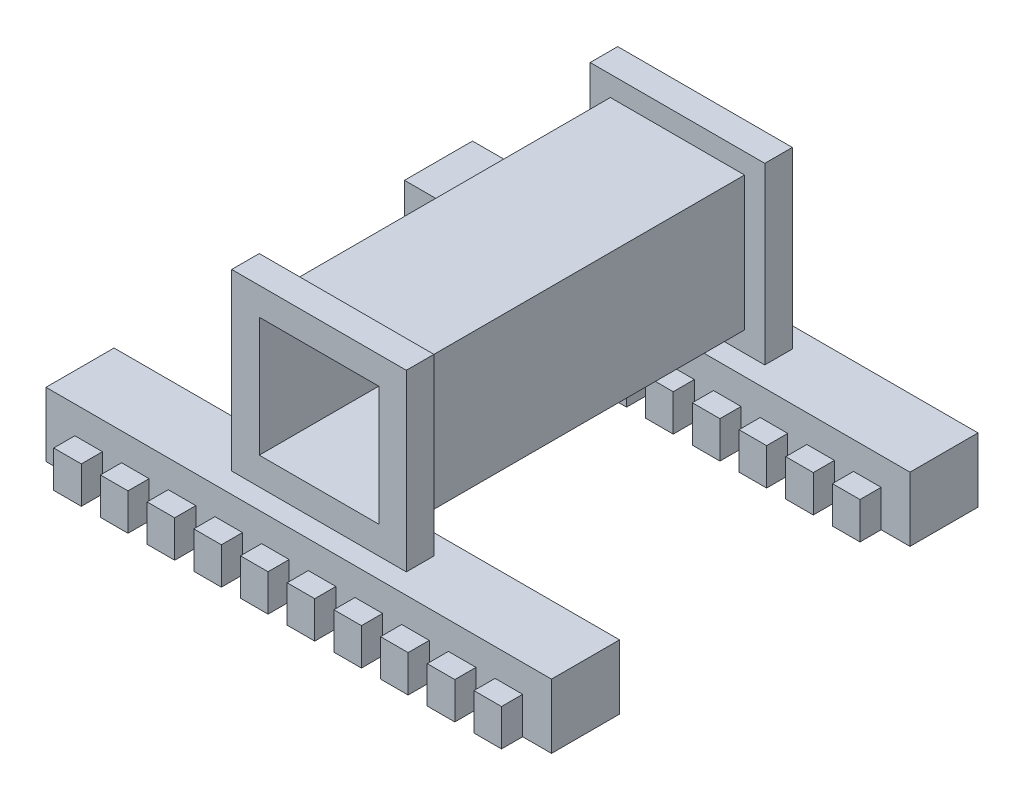
from build123d import *

# Parameters (mm, degrees)
EXTRUDE_1_DEPTH      = 21
SKETCH_1_3_W         = 13
SKETCH_1_3_H         = 13
CUT_EXTRUDE_1_DEPTH  = 21
SKETCH_1_12_W        = 19
SKETCH_1_12_H        = 19
SKETCH_1_12_W_2      = 14.6
SKETCH_1_12_H_2      = 14.6
SKETCH_1_12_W_3      = 13
SKETCH_1_12_H_3      = 13
CUT_EXTRUDE_6_DEPTH  = 18
CUT_EXTRUDE_7_DEPTH  = 14.5
SKETCH_4_W           = 3.504900739
SKETCH_4_H           = 7
SKETCH_4_W_2         = 3.5
EXTRUDE_2_DEPTH      = 27.5
SKETCH_10_W          = 1
SKETCH_10_H          = 7
EXTRUDE_4_DEPTH      = 55
SKETCH_14_W          = 1
SKETCH_14_H          = 7
EXTRUDE_6_DEPTH      = 55
CUT_EXTRUDE_17_DEPTH = 2.3
CUT_EXTRUDE_18_DEPTH = 2.3
CUT_EXTRUDE_19_DEPTH = 2.3
CUT_EXTRUDE_20_DEPTH = 2.3


with BuildPart() as part:
    # 草图1 → 凸台-拉伸1 (new, symmetric)
    with BuildSketch(Plane.XY):
        Polygon((9.5, 9.5), (-9.5, 9.5), (-9.5, -9.5), (-27.5, -9.5), (-27.5, -16.5), (27.5, -16.5), (27.5, -9.5), (9.5, -9.5), align=None)
    extrude(amount=EXTRUDE_1_DEPTH, both=True)

    # 草图1<3> → 切除-拉伸1 (cut, symmetric)
    with BuildSketch(Plane.XY):
        Rectangle(SKETCH_1_3_W, SKETCH_1_3_H)
    extrude(amount=CUT_EXTRUDE_1_DEPTH, both=True, mode=Mode.SUBTRACT)

    # 草图1<12> → 切除-拉伸6 (cut, symmetric)
    # profile 1 of 2: a face of its own
    with BuildSketch(Plane.XY):
        Rectangle(SKETCH_1_12_W, SKETCH_1_12_H)
        Rectangle(SKETCH_1_12_W_2, SKETCH_1_12_H_2, mode=Mode.SUBTRACT)
    # profile 2 of 2: a face of its own
    with BuildSketch(Plane.XY):
        Rectangle(SKETCH_1_12_W_3, SKETCH_1_12_H_3)
    extrude(amount=CUT_EXTRUDE_6_DEPTH, both=True, mode=Mode.SUBTRACT)

    # 草图1<13> → 切除-拉伸7 (cut, symmetric)
    with BuildSketch(Plane.XY):
        Polygon((9.5, -9.5), (-9.5, -9.5), (-27.5, -9.5), (-27.5, -16.5), (27.5, -16.5), (27.5, -9.5), align=None)
    extrude(amount=CUT_EXTRUDE_7_DEPTH, both=True, mode=Mode.SUBTRACT)

    # 草图4 → 凸台-拉伸2 (add, symmetric)
    with BuildSketch(Plane(origin=(0, 0, 0), x_dir=(0, 0, -1), z_dir=(1, 0, 0))):
        with Locations((-22.752450369, -13)):
            Rectangle(SKETCH_4_W, SKETCH_4_H)
        with Locations((22.75, -13)):
            Rectangle(SKETCH_4_W_2, SKETCH_4_H)
    extrude(amount=EXTRUDE_2_DEPTH, both=True)

    # 草图10 → 凸台-拉伸4 (add)
    with BuildSketch(Plane(origin=(27.5, 0, 0), x_dir=(0, 0, -1), z_dir=(1, 0, 0))):
        with Locations((-25.004900739, -13)):
            Rectangle(SKETCH_10_W, SKETCH_10_H)
        with Locations((-14, -13)):
            Rectangle(SKETCH_10_W, SKETCH_10_H)
    extrude(amount=-EXTRUDE_4_DEPTH)

    # 草图14 → 凸台-拉伸6 (add)
    with BuildSketch(Plane(origin=(27.5, 0, 0), x_dir=(0, 0, -1), z_dir=(1, 0, 0))):
        with Locations((14, -13)):
            Rectangle(SKETCH_14_W, SKETCH_14_H)
        with Locations((25, -13)):
            Rectangle(SKETCH_14_W, SKETCH_14_H)
    extrude(amount=-EXTRUDE_6_DEPTH)

    # 草图15 → 切除-拉伸17 (cut)
    with BuildSketch(Plane(origin=(0, 0, -25.5), x_dir=(-1, 0, 0), z_dir=(0, 0, -1))):
        Polygon((-27.5, -9.5), (-27.5, -16.5), (-24.36, -16.5), (-24.36, -12.5), (-22.86, -12.5), (-21.36, -12.5), (-21.36, -16.5), (-19.28, -16.5), (-19.28, -12.5), (-17.78, -12.5), (-16.28, -12.5), (-16.28, -16.5), (-14.2, -16.5), (-14.2, -12.5), (-12.7, -12.5), (-11.2, -12.5), (-11.2, -16.5), (-9.12, -16.5), (-9.12, -12.5), (-7.62, -12.5), (-6.12, -12.5), (-6.12, -16.5), (-4.04, -16.5), (-4.04, -12.5), (-2.54, -12.5), (-1.04, -12.5), (-1.04, -16.5), (1.04, -16.5), (1.04, -12.5), (2.54, -12.5), (4.04, -12.5), (4.04, -16.5), (6.12, -16.5), (6.12, -12.5), (7.62, -12.5), (9.12, -12.5), (9.12, -16.5), (11.2, -16.5), (11.2, -12.5), (12.7, -12.5), (14.2, -12.5), (14.2, -16.5), (16.28, -16.5), (16.28, -12.5), (17.78, -12.5), (19.28, -12.5), (19.28, -16.5), (21.36, -16.5), (21.36, -12.5), (22.86, -12.5), (24.36, -12.5), (24.36, -16.5), (27.5, -16.5), (27.5, -9.5), align=None)
    extrude(amount=-CUT_EXTRUDE_17_DEPTH, mode=Mode.SUBTRACT)

    # 草图16 → 切除-拉伸18 (cut)
    with BuildSketch(Plane(origin=(0, 0, 13.5), x_dir=(-1, 0, 0), z_dir=(0, 0, -1))):
        Polygon((27.5, -9.5), (-27.5, -9.5), (-27.5, -16.5), (-24.36, -16.5), (-24.36, -12.5), (-21.36, -12.5), (-21.36, -16.5), (-19.28, -16.5), (-19.28, -12.5), (-16.28, -12.5), (-16.28, -16.5), (-14.2, -16.5), (-14.2, -12.5), (-11.2, -12.5), (-11.2, -16.5), (-9.12, -16.5), (-9.12, -12.5), (-6.12, -12.5), (-6.12, -16.5), (-4.04, -16.5), (-4.04, -12.5), (-1.04, -12.5), (-1.04, -16.5), (1.04, -16.5), (1.04, -12.5), (4.04, -12.5), (4.04, -16.5), (6.12, -16.5), (6.12, -12.5), (9.12, -12.5), (9.12, -16.5), (11.2, -16.5), (11.2, -12.5), (14.2, -12.5), (14.2, -16.5), (16.28, -16.5), (16.28, -12.5), (19.28, -12.5), (19.28, -16.5), (21.36, -16.5), (21.36, -12.5), (24.36, -12.5), (24.36, -16.5), (27.5, -16.5), align=None)
    extrude(amount=-CUT_EXTRUDE_18_DEPTH, mode=Mode.SUBTRACT)

    # 草图17 → 切除-拉伸19 (cut)
    with BuildSketch(Plane.XY.offset(-13.5)):
        Polygon((24.36, -16.5), (27.5, -16.5), (27.5, -9.5), (-27.5, -9.5), (-27.5, -16.5), (-24.36, -16.5), (-24.36, -12.5), (-21.36, -12.5), (-21.36, -16.5), (-19.28, -16.5), (-19.28, -12.5), (-16.28, -12.5), (-16.28, -16.5), (-14.2, -16.5), (-14.2, -12.5), (-11.2, -12.5), (-11.2, -16.5), (-9.12, -16.5), (-9.12, -12.5), (-6.12, -12.5), (-6.12, -16.5), (-4.04, -16.5), (-4.04, -12.5), (-1.04, -12.5), (-1.04, -16.5), (1.04, -16.5), (1.04, -12.5), (4.04, -12.5), (4.04, -16.5), (6.12, -16.5), (6.12, -12.5), (9.12, -12.5), (9.12, -16.5), (11.2, -16.5), (11.2, -12.5), (14.2, -12.5), (14.2, -16.5), (16.28, -16.5), (16.28, -12.5), (19.28, -12.5), (19.28, -16.5), (21.36, -16.5), (21.36, -12.5), (24.36, -12.5), align=None)
    extrude(amount=-CUT_EXTRUDE_19_DEPTH, mode=Mode.SUBTRACT)

    # 草图18 → 切除-拉伸20 (cut)
    with BuildSketch(Plane.XY.offset(25.504900739)):
        Polygon((24.36, -16.5), (27.5, -16.5), (27.5, -9.5), (-27.5, -9.5), (-27.5, -16.5), (-24.36, -16.5), (-24.36, -12.5), (-21.36, -12.5), (-21.36, -16.5), (-19.28, -16.5), (-19.28, -12.5), (-16.28, -12.5), (-16.28, -16.5), (-14.2, -16.5), (-14.2, -12.5), (-11.2, -12.5), (-11.2, -16.5), (-9.12, -16.5), (-9.12, -12.5), (-6.12, -12.5), (-6.12, -16.5), (-4.04, -16.5), (-4.04, -12.5), (-1.04, -12.5), (-1.04, -16.5), (1.04, -16.5), (1.04, -12.5), (4.04, -12.5), (4.04, -16.5), (6.12, -16.5), (6.12, -12.5), (9.12, -12.5), (9.12, -16.5), (11.2, -16.5), (11.2, -12.5), (14.2, -12.5), (14.2, -16.5), (16.28, -16.5), (16.28, -12.5), (19.28, -12.5), (19.28, -16.5), (21.36, -16.5), (21.36, -12.5), (24.36, -12.5), align=None)
    extrude(amount=-CUT_EXTRUDE_20_DEPTH, mode=Mode.SUBTRACT)


solid = part.part
